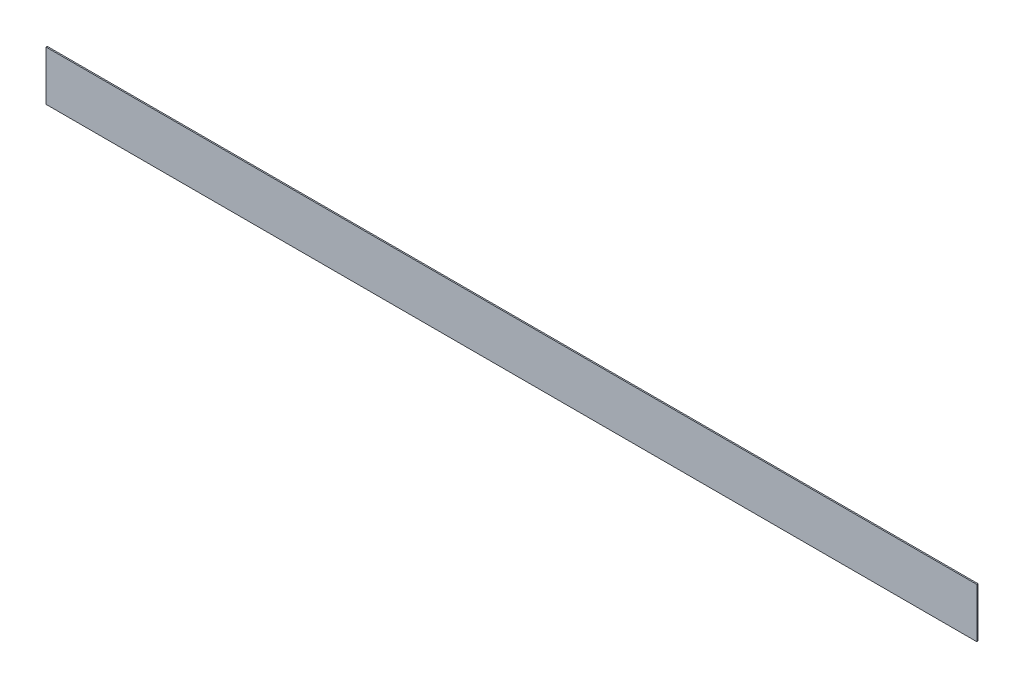
from build123d import *

# Parameters (mm, degrees)
SKETCH1_W           = 75
SKETCH1_H           = 4
BOSS_EXTRUDE1_DEPTH = 0.1


with BuildPart() as part:
    # Sketch1 → Boss-Extrude1 (new body)
    with BuildSketch(Plane.XY):
        with Locations((37.5, -2)):
            Rectangle(SKETCH1_W, SKETCH1_H)
    extrude(amount=BOSS_EXTRUDE1_DEPTH)


solid = part.part
